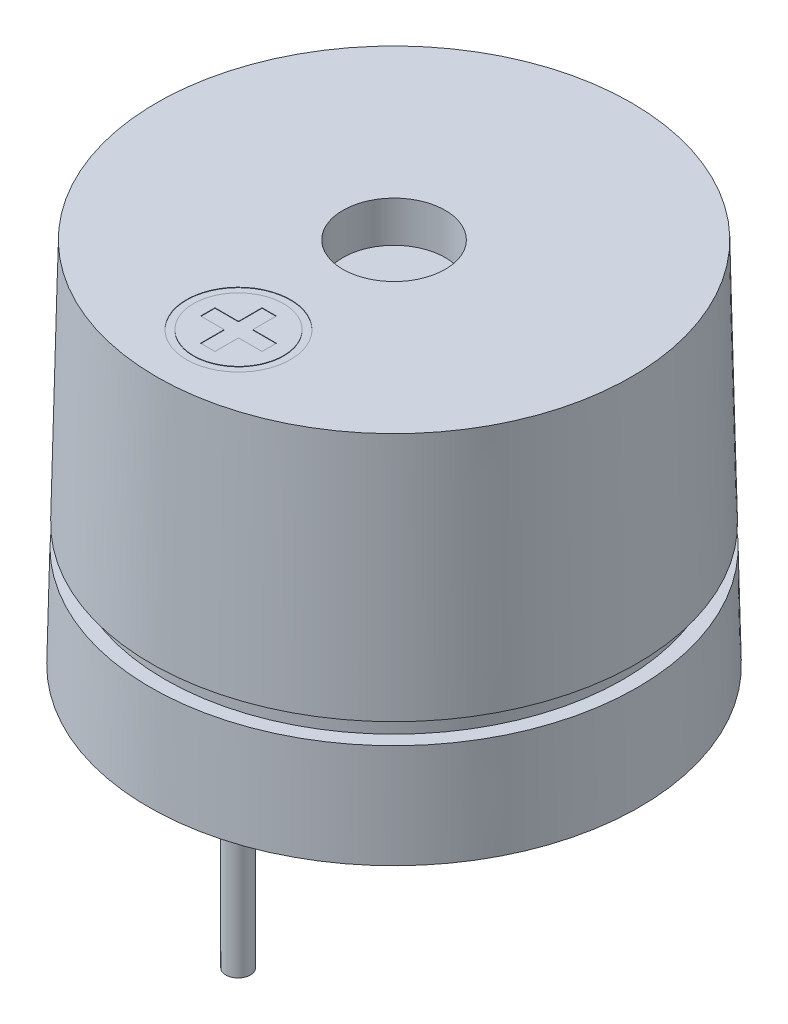
from build123d import *

# Parameters (mm, degrees)
SKETCH2_R           = 5.4
CUT_EXTRUDE1_DEPTH  = 0.5
SKETCH4_R           = 0.3
BOSS_EXTRUDE2_DEPTH = 5
SKETCH5_R           = 1.27
SKETCH5_R_2         = 1.1
CUT_EXTRUDE2_DEPTH  = 0.01
CUT_EXTRUDE3_DEPTH  = 0.01
SKETCH7_R           = 1.25
CUT_EXTRUDE4_DEPTH  = 3
SKETCH8_R           = 4.5
CUT_EXTRUDE5_DEPTH  = 2
SKETCH12_R          = 1.25
BOSS_EXTRUDE4_DEPTH = 0.5
BOSS_EXTRUDE4_TAPER = 45
FILLET3_R           = 1
SKETCH13_W          = 1
SKETCH13_H          = 0.5


with BuildPart() as part:
    # Sketch1 → Revolve1 (revolve)
    with BuildSketch(Plane.XY):
        Polygon((0, 0), (0, 9), (5.8, 9), (6, 0), align=None)
    revolve(axis=Axis((0, 0, 0), (0, 1, 0)))

    # Sketch2 → Cut-Extrude1 (cut)
    with BuildSketch(Plane.XZ):
        Circle(SKETCH2_R)
    extrude(amount=-CUT_EXTRUDE1_DEPTH, mode=Mode.SUBTRACT)

    # Sketch4 → Boss-Extrude2 (add)
    with BuildSketch(Plane.XZ.offset(-0.5)):
        with Locations((0, -3.81)):
            Circle(SKETCH4_R)
        with Locations((0, 3.81)):
            Circle(SKETCH4_R)
    extrude(amount=BOSS_EXTRUDE2_DEPTH)

    # Sketch5 → Cut-Extrude2 (cut)
    with BuildSketch(Plane(origin=(0, 9, 0), x_dir=(1, 0, 0), z_dir=(0, 1, 0))):
        with Locations((0, -3.8)):
            Circle(SKETCH5_R)
        with Locations((0, -3.8)):
            Circle(SKETCH5_R_2, mode=Mode.SUBTRACT)
    extrude(amount=-CUT_EXTRUDE2_DEPTH, mode=Mode.SUBTRACT)

    # Sketch6 → Cut-Extrude3 (cut)
    with BuildSketch(Plane(origin=(0, 9, 0), x_dir=(1, 0, 0), z_dir=(0, 1, 0))):
        Polygon((-0.175, -3.05), (0.175, -3.05), (0.175, -3.625), (0.75, -3.625), (0.75, -3.975), (0.175, -3.975), (0.175, -4.55), (-0.175, -4.55), (-0.175, -3.975), (-0.75, -3.975), (-0.75, -3.625), (-0.175, -3.625), align=None)
    extrude(amount=-CUT_EXTRUDE3_DEPTH, mode=Mode.SUBTRACT)

    # Sketch7 → Cut-Extrude4 (cut)
    with BuildSketch(Plane(origin=(0, 9, 0), x_dir=(1, 0, 0), z_dir=(0, 1, 0))):
        Circle(SKETCH7_R)
    extrude(amount=-CUT_EXTRUDE4_DEPTH, mode=Mode.SUBTRACT)

    # Sketch8 → Cut-Extrude5 (cut)
    with BuildSketch(Plane(origin=(0, 6, 0), x_dir=(1, 0, 0), z_dir=(0, 1, 0))):
        Circle(SKETCH8_R)
    extrude(amount=CUT_EXTRUDE5_DEPTH, mode=Mode.SUBTRACT)

    # Sketch12 → Boss-Extrude4 (add)
    with BuildSketch(Plane.XZ.offset(-0.5)):
        with Locations((0, 3.81)):
            Circle(SKETCH12_R)
        with Locations((0, -3.81)):
            Circle(SKETCH12_R)
    extrude(amount=BOSS_EXTRUDE4_DEPTH, taper=BOSS_EXTRUDE4_TAPER)

    # Fillet3
    fillet3_edges = [part.edges().sort_by_distance(p)[0] for p in [
        (-0.75, 0, 3.81),
        (-0.75, 0, -3.81),
    ]]
    fillet(fillet3_edges, radius=FILLET3_R)

    # Sketch13 → Cut-Revolve1 (revolve, cut)
    with BuildSketch(Plane.XY):
        with Locations((6.1, 2.75)):
            Rectangle(SKETCH13_W, SKETCH13_H)
    revolve(axis=Axis((0, 0, 0), (0, 1, 0)), mode=Mode.SUBTRACT)


solid = part.part
